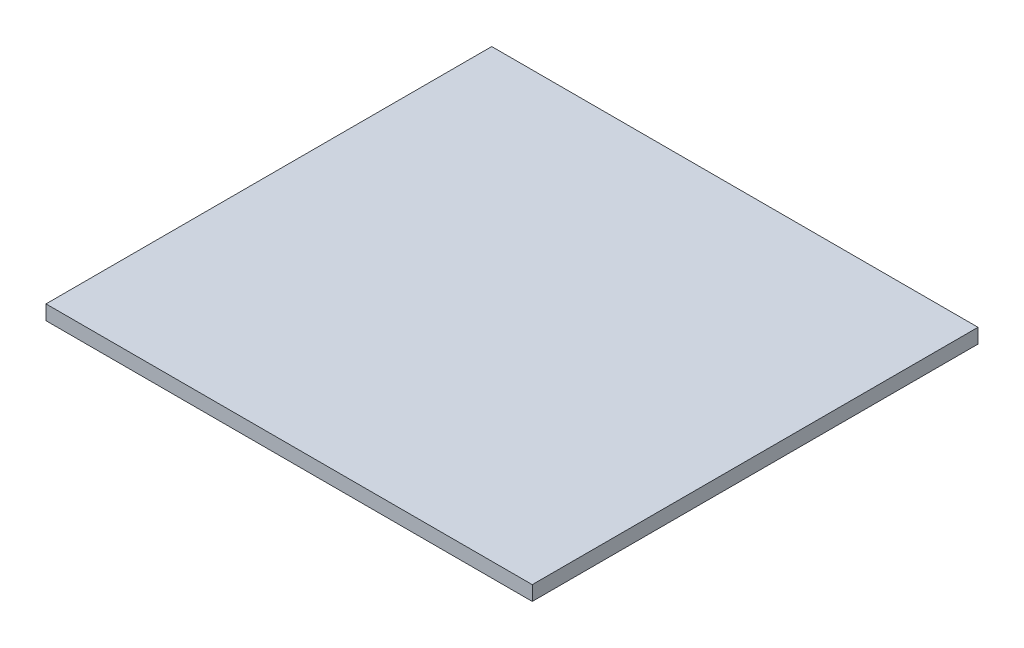
from build123d import *

# Parameters (mm, degrees)
SKETCH_1_W      = 600
SKETCH_1_H      = 550
EXTRUDE_1_DEPTH = 18


with BuildPart() as part:
    # Эскиз1 → Бобышка-Вытянуть1 (new body)
    with BuildSketch(Plane(origin=(0, 0, 0), x_dir=(1, 0, 0), z_dir=(0, 1, 0))):
        Rectangle(SKETCH_1_W, SKETCH_1_H)
    extrude(amount=EXTRUDE_1_DEPTH)


solid = part.part
